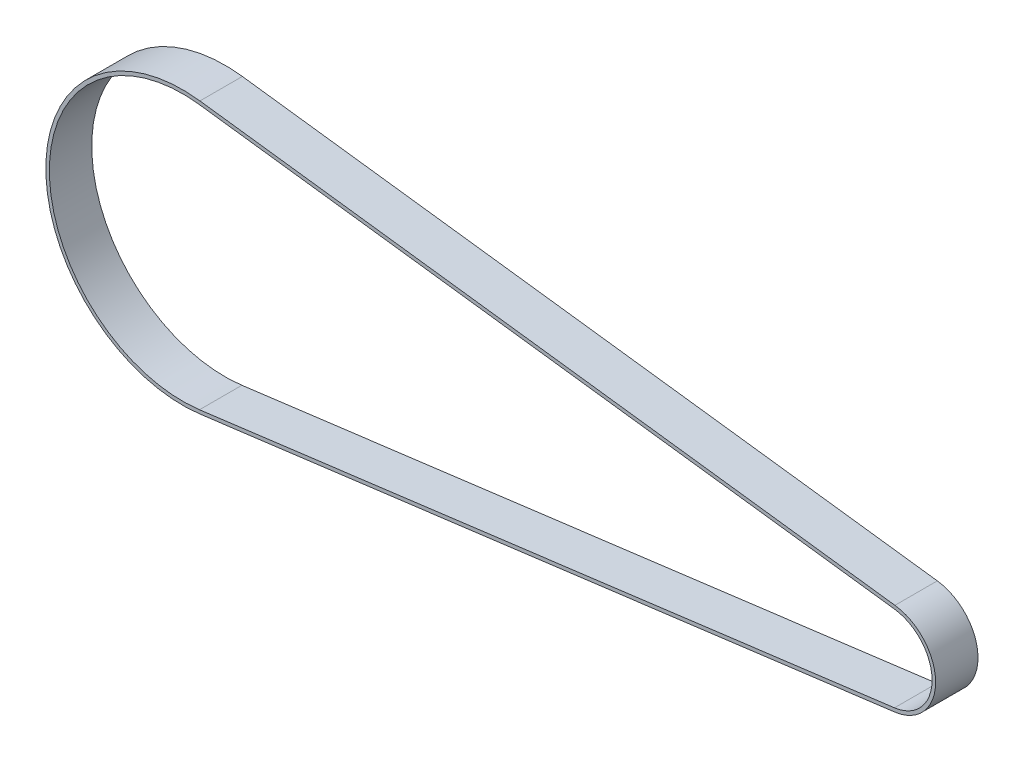
from build123d import *

# Parameters (mm, degrees)
SALIENTE_EXTRUIR1_DEPTH = 6


with BuildPart() as part:
    # Croquis1 → Saliente-Extruir1 (new body)
    with BuildSketch(Plane.XY):
        with BuildLine():
            Line((100.8415, -6.546134566), (2.467125, -19.19207634))
            ThreePointArc((2.467125, -19.19207634), (-19.35, 0), (2.467125, 19.19207634))
            Line((2.467125, 19.19207634), (100.8415, 6.546134566))
            ThreePointArc((100.8415, 6.546134566), (106.6, 0), (100.8415, -6.546134566))
        make_face()
        with BuildLine():
            Line((2.403375, 18.696157055), (100.77775, 6.05021528))
            ThreePointArc((100.77775, 6.05021528), (106.1, 0), (100.77775, -6.05021528))
            Line((100.77775, -6.05021528), (2.403375, -18.696157055))
            ThreePointArc((2.403375, -18.696157055), (-18.85, 0), (2.403375, 18.696157055))
        make_face(mode=Mode.SUBTRACT)
    extrude(amount=SALIENTE_EXTRUIR1_DEPTH)


solid = part.part
